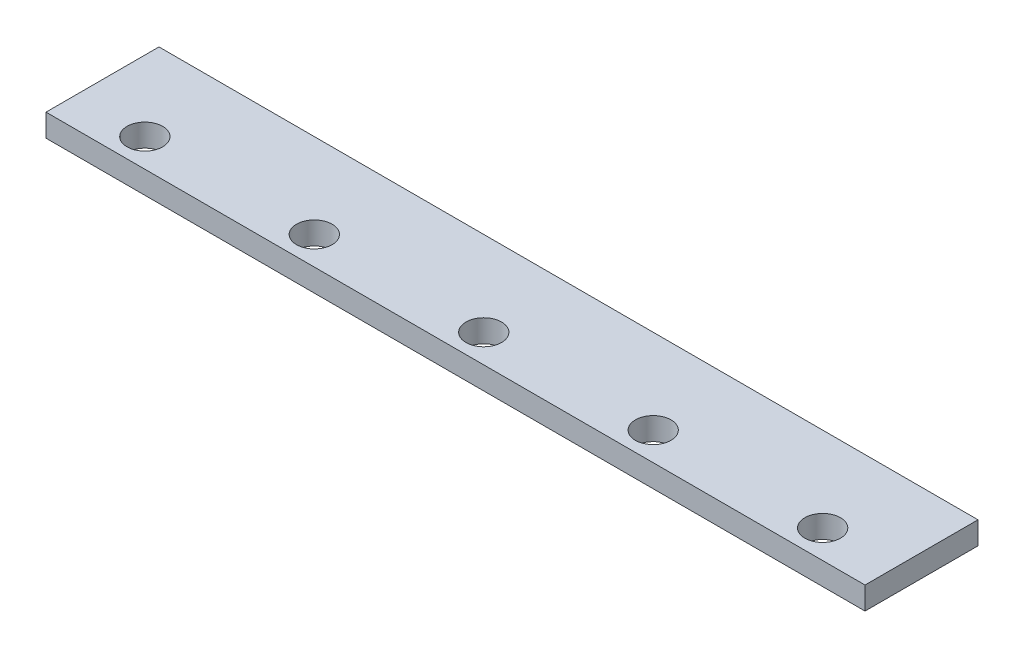
from build123d import *

# Parameters (mm, degrees)
SKETCH1_W           = 580
SKETCH1_H           = 80
BOSS_EXTRUDE1_DEPTH = 16
SKETCH2_R           = 12.6
CUT_EXTRUDE1_DEPTH  = 16
LPATTERN2_COUNT     = 5
LPATTERN2_PITCH     = 120


with BuildPart() as part:
    # Sketch1 → Boss-Extrude1 (new body)
    with BuildSketch(Plane(origin=(0, 0, 0), x_dir=(1, 0, 0), z_dir=(0, 1, 0))):
        Rectangle(SKETCH1_W, SKETCH1_H)
    extrude(amount=BOSS_EXTRUDE1_DEPTH)

    # Sketch2 → Cut-Extrude1 (cut)
    with BuildSketch(Plane(origin=(0, 16, 0), x_dir=(1, 0, 0), z_dir=(0, 1, 0))):
        with Locations(Location((-240, -20, 0), (0, 0, 270))):  # turned: the seam where the file's is
            Circle(SKETCH2_R)
    cut_extrude1 = extrude(amount=-CUT_EXTRUDE1_DEPTH, mode=Mode.SUBTRACT)

    # LPattern2: Cut-Extrude1 ×5
    with Locations(*[(i * LPATTERN2_PITCH, 0, 0) for i in range(1, LPATTERN2_COUNT)]):
        add(cut_extrude1, mode=Mode.SUBTRACT)


solid = part.part
